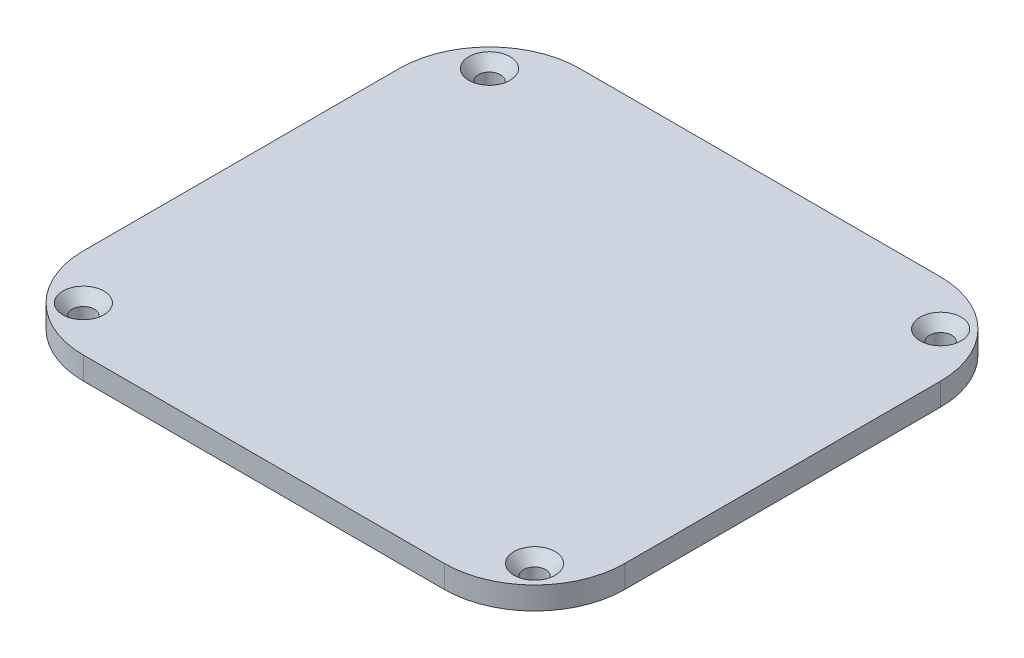
from build123d import *

# Parameters (mm, degrees)
BOSS_EXTRUDE1_DEPTH                               = 5
BOSS_EXTRUDE2_DEPTH                               = 4.4
CUT_EXTRUDE2_START                                = -5
SKETCH4_R                                         = 4.9
CUT_EXTRUDE2_DEPTH                                = 1.5
CSK_FOR_8_FLAT_HEAD_SOCKET_CAP_SCREW1_D           = 4.9149
CSK_FOR_8_FLAT_HEAD_SOCKET_CAP_SCREW1_DEPTH       = 68.34
CSK_FOR_8_FLAT_HEAD_SOCKET_CAP_SCREW1_CSINK_D     = 9.1186
CSK_FOR_8_FLAT_HEAD_SOCKET_CAP_SCREW1_CSINK_ANGLE = 82
CSK_FOR_8_FLAT_HEAD_SOCKET_CAP_SCREW1_TIP         = 1.476584928


with BuildPart() as part:
    # Sketch1 → Boss-Extrude1 (new body)
    with BuildSketch(Plane(origin=(0, 0, 0), x_dir=(1, 0, 0), z_dir=(0, 1, 0))):
        with BuildLine():
            Line((-60, -30), (-60, 40))
            ThreePointArc((-60, 40), (-54.142135624, 54.142135624), (-40, 60))
            Line((-40, 60), (40, 60))
            ThreePointArc((40, 60), (54.142135624, 54.142135624), (60, 40))
            Line((60, 40), (60, -30))
            ThreePointArc((60, -30), (54.142135624, -44.142135624), (40, -50))
            Line((40, -50), (-40, -50))
            ThreePointArc((-40, -50), (-54.142135624, -44.142135624), (-60, -30))
        make_face()
    extrude(amount=BOSS_EXTRUDE1_DEPTH)

    # Sketch1_5 → Boss-Extrude2 (add)
    with BuildSketch(Plane(origin=(0, 0, 0), x_dir=(1, 0, 0), z_dir=(0, 1, 0))):
        with BuildLine():
            Line((-39.4, -22.6), (41.9, -22.6))
            Line((41.9, -22.6), (41.9, -32))
            ThreePointArc((41.9, -32), (39.146803743, -38.646803743), (32.5, -41.4))
            Line((32.5, -41.4), (-30, -41.4))
            ThreePointArc((-30, -41.4), (-36.646803743, -38.646803743), (-39.4, -32))
            Line((-39.4, -32), (-39.4, -22.6))
        make_face()
        with BuildLine():
            Line((3.1, 54.4), (3.1, 30.6))
            Line((3.1, 30.6), (41.9, 30.6))
            Line((41.9, 30.6), (41.9, 43))
            ThreePointArc((41.9, 43), (38.561017306, 51.061017306), (30.5, 54.4))
            Line((30.5, 54.4), (3.1, 54.4))
        make_face()
    extrude(amount=-BOSS_EXTRUDE2_DEPTH)

    # Sketch4 → Cut-Extrude2 (cut)
    with BuildSketch(Plane(origin=(0, 5, 0), x_dir=(1, 0, 0), z_dir=(0, 1, 0)).offset(CUT_EXTRUDE2_START)):
        with Locations((-20.2, -7)):
            Circle(SKETCH4_R)
        with Locations((-43.84, -2.83)):
            Circle(SKETCH4_R)
        with Locations((3.44, 12.83)):
            Circle(SKETCH4_R)
        with Locations((44.41, -4.14)):
            Circle(SKETCH4_R)
        with Locations((27.44, 12.83)):
            Circle(SKETCH4_R)
    extrude(amount=CUT_EXTRUDE2_DEPTH, mode=Mode.SUBTRACT)

    # CSK for _8 Flat Head Socket Cap Screw1
    with Locations(Plane(origin=(50, 5, 40), x_dir=(0, 0, 1), z_dir=(0, 1, 0))):
        with Locations((0, 0), (-90, 0), (-90, -100), (0, -100)):
            CounterSinkHole(CSK_FOR_8_FLAT_HEAD_SOCKET_CAP_SCREW1_D / 2, CSK_FOR_8_FLAT_HEAD_SOCKET_CAP_SCREW1_CSINK_D / 2, depth=CSK_FOR_8_FLAT_HEAD_SOCKET_CAP_SCREW1_DEPTH, counter_sink_angle=CSK_FOR_8_FLAT_HEAD_SOCKET_CAP_SCREW1_CSINK_ANGLE)
            with Locations((0, 0, -(CSK_FOR_8_FLAT_HEAD_SOCKET_CAP_SCREW1_DEPTH + CSK_FOR_8_FLAT_HEAD_SOCKET_CAP_SCREW1_TIP / 2))):  # 118° drill point
                Cone(0, CSK_FOR_8_FLAT_HEAD_SOCKET_CAP_SCREW1_D / 2, CSK_FOR_8_FLAT_HEAD_SOCKET_CAP_SCREW1_TIP, mode=Mode.SUBTRACT)


solid = part.part
